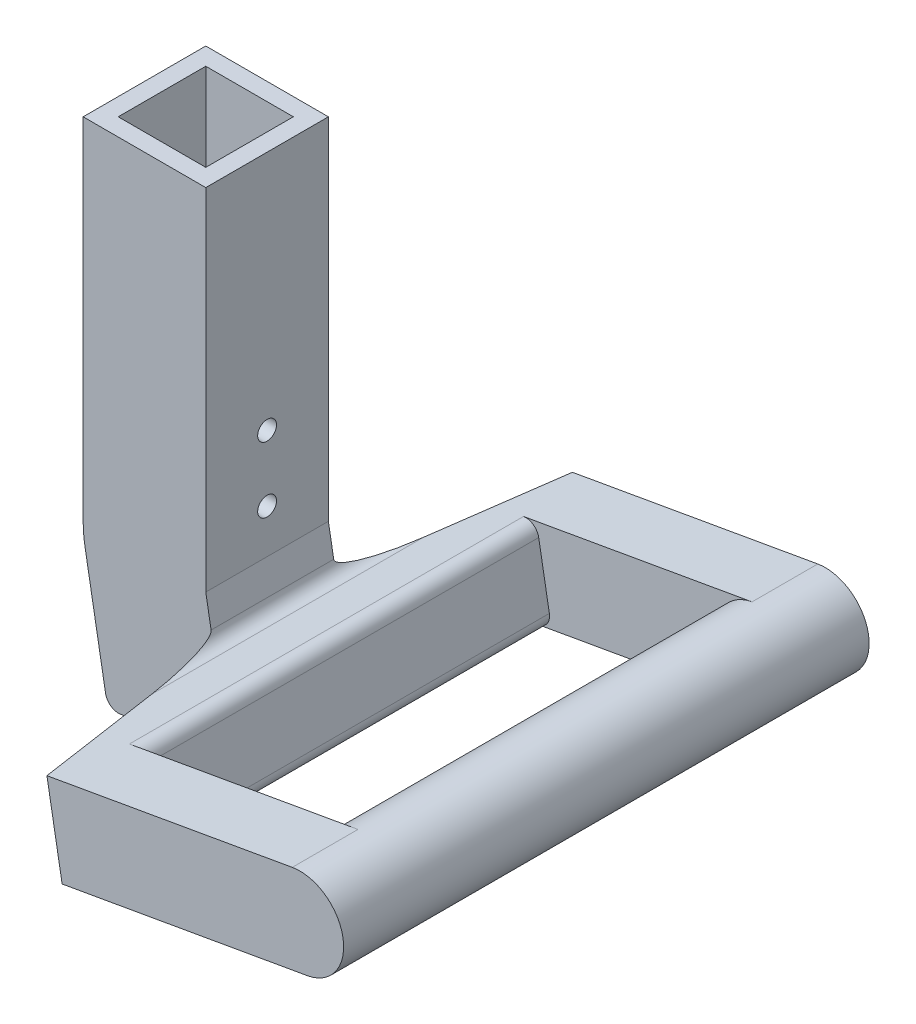
from build123d import *

# Parameters (mm, degrees)
SKETCH1_W                       = 28
SKETCH1_H                       = 28
SKETCH1_W_2                     = 20
SKETCH1_H_2                     = 20
BOSS_EXTRUDE1_DEPTH             = 30
SKETCH2_W                       = 28
SKETCH2_H                       = 28
BOSS_EXTRUDE2_DEPTH             = 3
SKETCH3_R                       = 2.15
CUT_EXTRUDE1_DEPTH              = 48.539457296
BOSS_EXTRUDE3_DEPTH             = 28
BOSS_EXTRUDE4_DEPTH             = 20
BOSS_EXTRUDE5_REACH             = 146.565
SKETCH6_R                       = 10
BOSS_EXTRUDE5_DIRECTION_2_REACH = 146.565
SKETCH7_W                       = 28
SKETCH7_H                       = 28
SKETCH7_W_2                     = 20
SKETCH7_H_2                     = 20
BOSS_EXTRUDE6_DEPTH             = 50
FILLET1_R                       = 3


with BuildPart() as part:
    # Sketch1 → Boss-Extrude1 (new body)
    with BuildSketch(Plane(origin=(0, 0, 0), x_dir=(1, 0, 0), z_dir=(0, 1, 0))):
        with Locations((10, 10)):
            Rectangle(SKETCH1_W, SKETCH1_H)
        with Locations((10, 10)):
            Rectangle(SKETCH1_W_2, SKETCH1_H_2, mode=Mode.SUBTRACT)
    extrude(amount=BOSS_EXTRUDE1_DEPTH)

    # Sketch2 → Boss-Extrude2 (add)
    with BuildSketch(Plane.XZ):
        with Locations((10, -10)):
            Rectangle(SKETCH2_W, SKETCH2_H)
    extrude(amount=-BOSS_EXTRUDE2_DEPTH)

    # Sketch3 → Cut-Extrude1 (cut, through all)
    with BuildSketch(Plane(origin=(24, 0, 0), x_dir=(0, 0, -1), z_dir=(1, 0, 0))):
        with Locations((10, 25)):
            Circle(SKETCH3_R)
        with Locations((10, 10)):
            Circle(SKETCH3_R)
    extrude(amount=-CUT_EXTRUDE1_DEPTH, mode=Mode.SUBTRACT)

    # Sketch4 → Boss-Extrude3 (add)
    with BuildSketch(Plane.XY.offset(4)):
        with BuildLine():
            Line((24, 0), (29.20944533, -29.54423259))
            Line((29.20944533, -29.54423259), (1.634828246, -34.406381565))
            Line((1.634828246, -34.406381565), (-3.574617084, -4.862148975))
            ThreePointArc((-3.574617084, -4.862148975), (-3.893451547, -2.440360797), (-4, 0))
            Line((-4, 0), (24, 0))
        make_face()
    extrude(amount=-BOSS_EXTRUDE3_DEPTH)

    # Sketch5 → Boss-Extrude4 (add)
    with BuildSketch(Plane(origin=(5.933133881, -33.64847431, 0), x_dir=(0, 0, -1), z_dir=(0.1736481776669318, -0.9848077530122078, 0))):
        Polygon((24, 23.635386072), (-4, 23.635386072), (-50, 31.746427185), (-50, 88.635386072), (-35, 88.635386072), (-35, 38.635386072), (55, 38.635386072), (55, 88.635386072), (70, 88.635386072), (70, 31.746427185), align=None)
    extrude(amount=-BOSS_EXTRUDE4_DEPTH)

    # Boss-Extrude5: up to this face of the body (flat: up to its plane)
    boss_extrude5_end = Plane(part.part.faces().sort_by_distance((63.473123613, -13.348355532, 50))[0])
    # Sketch6 → Boss-Extrude5 (add, up to the picked face)
    with BuildSketch(Plane.XY.offset(-55), mode=Mode.PRIVATE) as boss_extrude5_sk1:
        with Locations(Location((91.485467499, -8.409023512, 0), (0, 0, 100))):
            Circle(SKETCH6_R)
    boss_extrude5_tool1 = split(extrude(boss_extrude5_sk1.sketch, amount=BOSS_EXTRUDE5_REACH, mode=Mode.PRIVATE), bisect_by=boss_extrude5_end, keep=Keep.BOTH, mode=Mode.PRIVATE)
    add(boss_extrude5_tool1.solids().sort_by(Axis((91.485467, -8.409024, -55), (0, 0, 1)))[0])

    # Boss-Extrude5 direction 2: up to this face of the body (flat: up to its plane)
    boss_extrude5_direction_2_end = Plane(part.part.faces().sort_by_distance((63.473123613, -13.348355532, -70))[0])
    # Sketch6 → Boss-Extrude5 direction 2 (add, up to the picked face)
    with BuildSketch(Plane.XY.offset(-55), mode=Mode.PRIVATE) as boss_extrude5_direction_2_sk1:
        with Locations(Location((91.485467499, -8.409023512, 0), (0, 0, 100))):
            Circle(SKETCH6_R)
    boss_extrude5_direction_2_tool1 = split(extrude(boss_extrude5_direction_2_sk1.sketch, amount=-BOSS_EXTRUDE5_DIRECTION_2_REACH, mode=Mode.PRIVATE), bisect_by=boss_extrude5_direction_2_end, keep=Keep.BOTH, mode=Mode.PRIVATE)
    add(boss_extrude5_direction_2_tool1.solids().sort_by(Axis((91.485467, -8.409024, -55), (0, 0, -1)))[0])

    # Sketch7 → Boss-Extrude6 (add)
    with BuildSketch(Plane(origin=(0, 30, 0), x_dir=(1, 0, 0), z_dir=(0, 1, 0))):
        with Locations((10, 10)):
            Rectangle(SKETCH7_W, SKETCH7_H)
        with Locations((10, 10)):
            Rectangle(SKETCH7_W_2, SKETCH7_H_2, mode=Mode.SUBTRACT)
    extrude(amount=BOSS_EXTRUDE6_DEPTH)

    # Fillet1
    fillet1_edges = [part.edges().sort_by_distance(p)[0] for p in [
        (1.634828246, -34.406381565, -10),
        (25.736481777, -9.84807753, -10),
        (40.508598072, -7.243354865, -10),
        (43.981561625, -26.939509925, -10),
    ]]
    fillet(fillet1_edges, radius=FILLET1_R)


solid = part.part
